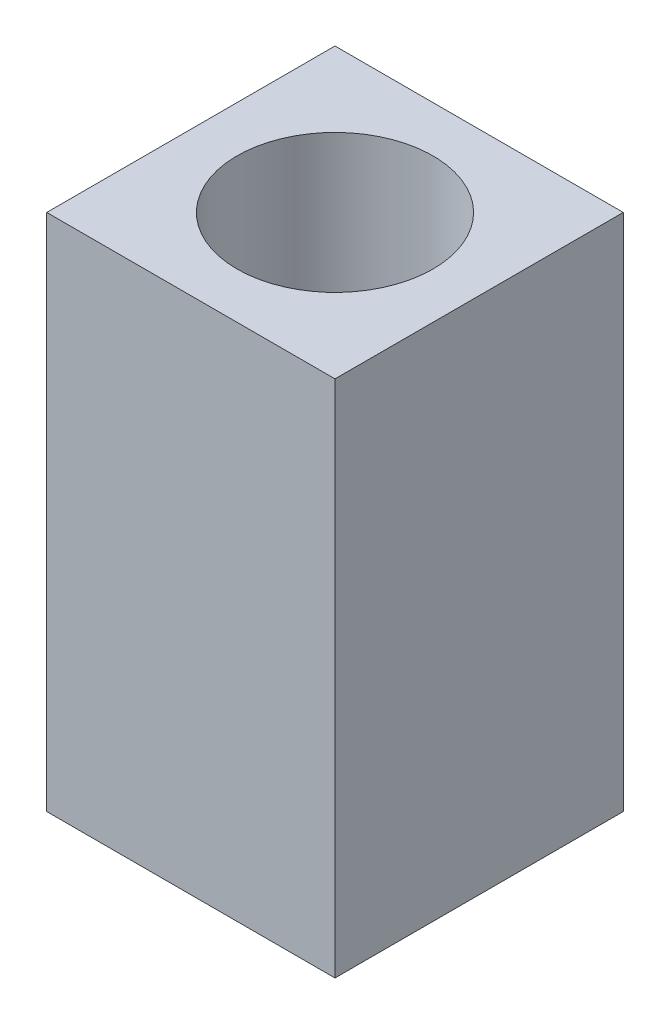
from build123d import *

# Parameters (mm, degrees)
SKETCH1_W           = 5
SKETCH1_H           = 5
SKETCH1_R           = 1.7
BOSS_EXTRUDE1_DEPTH = 9


with BuildPart() as part:
    # Sketch1 → Boss-Extrude1 (new body)
    with BuildSketch(Plane(origin=(0, 0, 0), x_dir=(1, 0, 0), z_dir=(0, 1, 0))):
        Rectangle(SKETCH1_W, SKETCH1_H)
        Circle(SKETCH1_R, mode=Mode.SUBTRACT)
    extrude(amount=BOSS_EXTRUDE1_DEPTH)


solid = part.part
